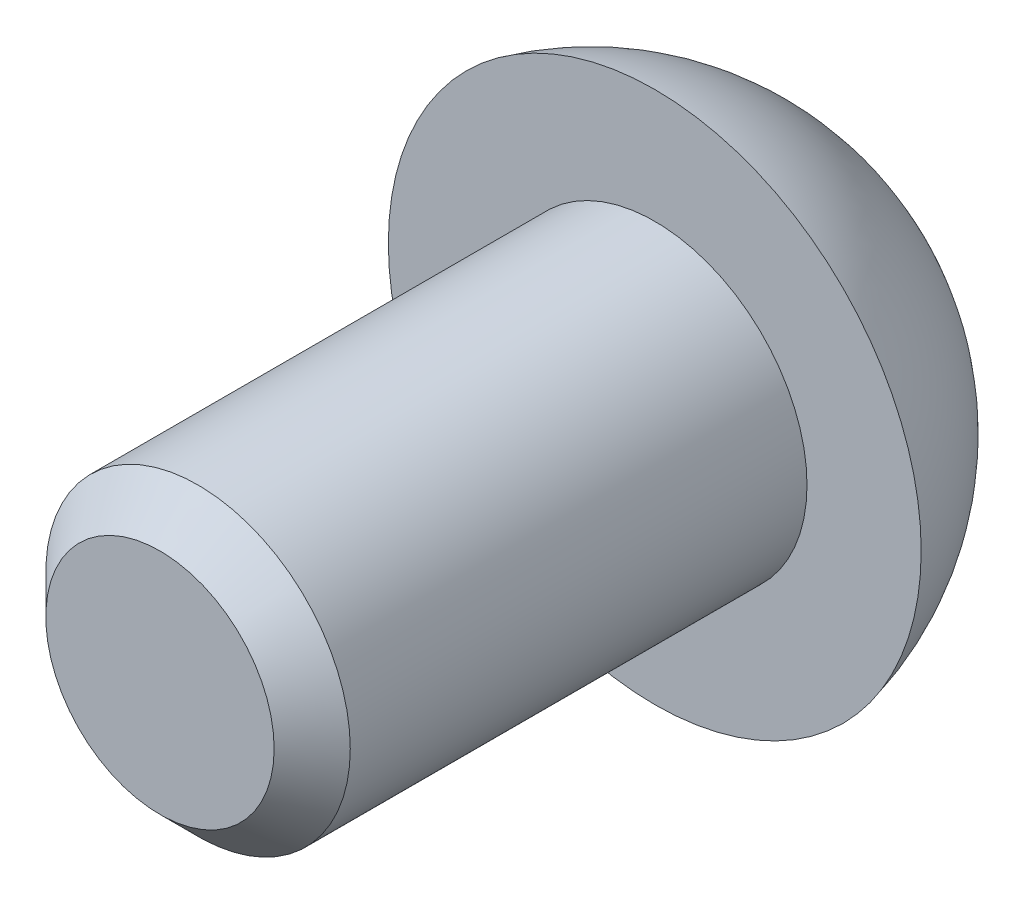
from build123d import *

# Parameters (mm, degrees)
SKETCH1_R           = 2
BOSS_EXTRUDE1_DEPTH = 6.5
CHAMFER1_SIZE       = 0.5


with BuildPart() as part:
    # Sketch1 → Boss-Extrude1 (new body)
    with BuildSketch(Plane.XY):
        Circle(SKETCH1_R)
    extrude(amount=-BOSS_EXTRUDE1_DEPTH)

    # Chamfer1
    chamfer1_edges = [part.edges().sort_by_distance(p)[0] for p in [
        (-2, 0, 0),
    ]]
    chamfer(chamfer1_edges, length=CHAMFER1_SIZE)

    # Sketch2 → Revolve1 (revolve)
    with BuildSketch(Plane(origin=(0, 0, 0), x_dir=(0, 0, -1), z_dir=(1, 0, 0))):
        with BuildLine():
            Line((6.5, 0), (6.5, 3.5))
            ThreePointArc((6.5, 3.5), (8.485229955, 2.227844932), (9.257385023, 0))
            Line((9.257385023, 0), (6.5, 0))
        make_face()
    revolve(axis=Axis((0, 0, -3.742614977), (0, 0, -1)))


solid = part.part
